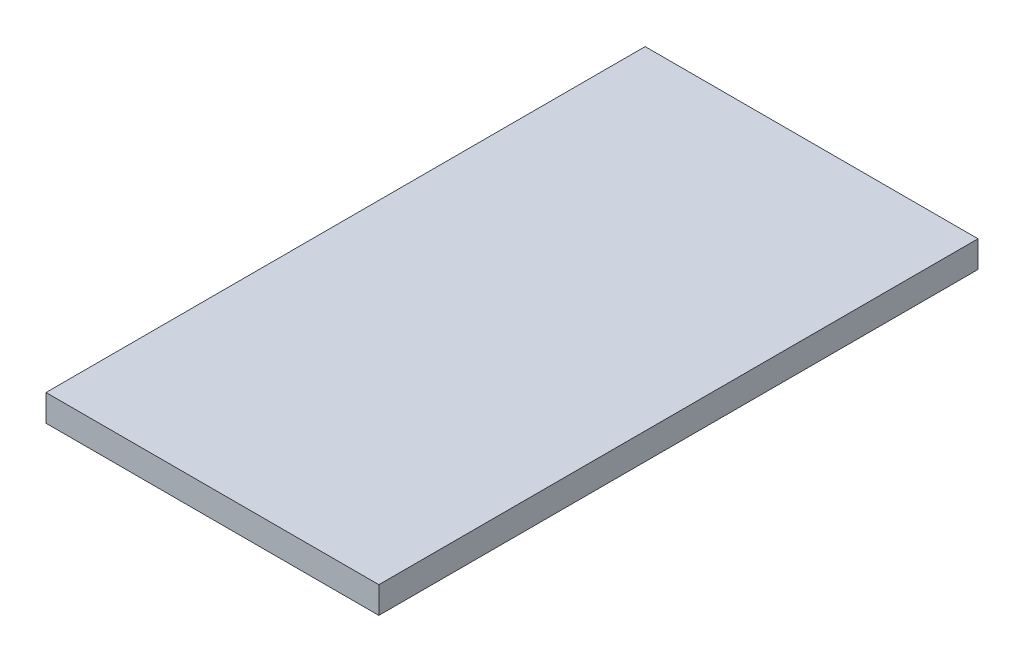
from build123d import *

# Parameters (mm, degrees)
SKETCH1_W           = 25
SKETCH1_H           = 45
BOSS_EXTRUDE1_DEPTH = 2


with BuildPart() as part:
    # Sketch1 → Boss-Extrude1 (new body)
    with BuildSketch(Plane(origin=(0, 0, 0), x_dir=(1, 0, 0), z_dir=(0, 1, 0))):
        Rectangle(SKETCH1_W, SKETCH1_H)
    extrude(amount=BOSS_EXTRUDE1_DEPTH)


solid = part.part
